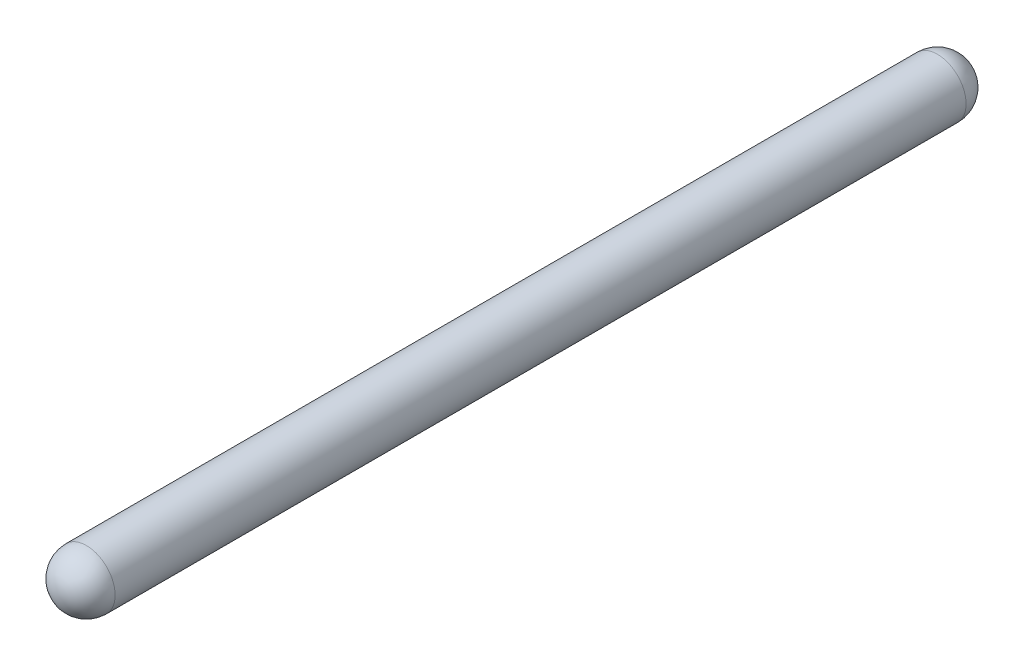
from build123d import *

# Parameters (mm, degrees)
SKETCH1_R           = 10.922
BOSS_EXTRUDE1_DEPTH = 161.925


with BuildPart() as part:
    # Sketch1 → Boss-Extrude1 (new body, symmetric)
    with BuildSketch(Plane.XY):
        with Locations((-85.411167397, 272.8722)):
            Circle(SKETCH1_R)
    extrude(amount=BOSS_EXTRUDE1_DEPTH, both=True)

    # Sketch3 → Revolve2 (revolve)
    with BuildSketch(Plane(origin=(0, 0, -161.925), x_dir=(-1, 0, 0), z_dir=(0, 0, -1))):
        with BuildLine():
            Line((74.489167397, 272.8722), (96.333167397, 272.8722))
            ThreePointArc((96.333167397, 272.8722), (85.411167397, 283.7942), (74.489167397, 272.8722))
        make_face()
    revolve(axis=Axis((-74.489167397, 272.8722, -161.925), (-1, 0, 0)))

    # Sketch4 → Revolve3 (revolve)
    with BuildSketch(Plane.XY.offset(161.925)):
        with BuildLine():
            Line((-74.489167397, 272.8722), (-96.333167397, 272.8722))
            ThreePointArc((-96.333167397, 272.8722), (-85.411167397, 283.7942), (-74.489167397, 272.8722))
        make_face()
    revolve(axis=Axis((-74.489167397, 272.8722, 161.925), (-1, 0, 0)))


solid = part.part
